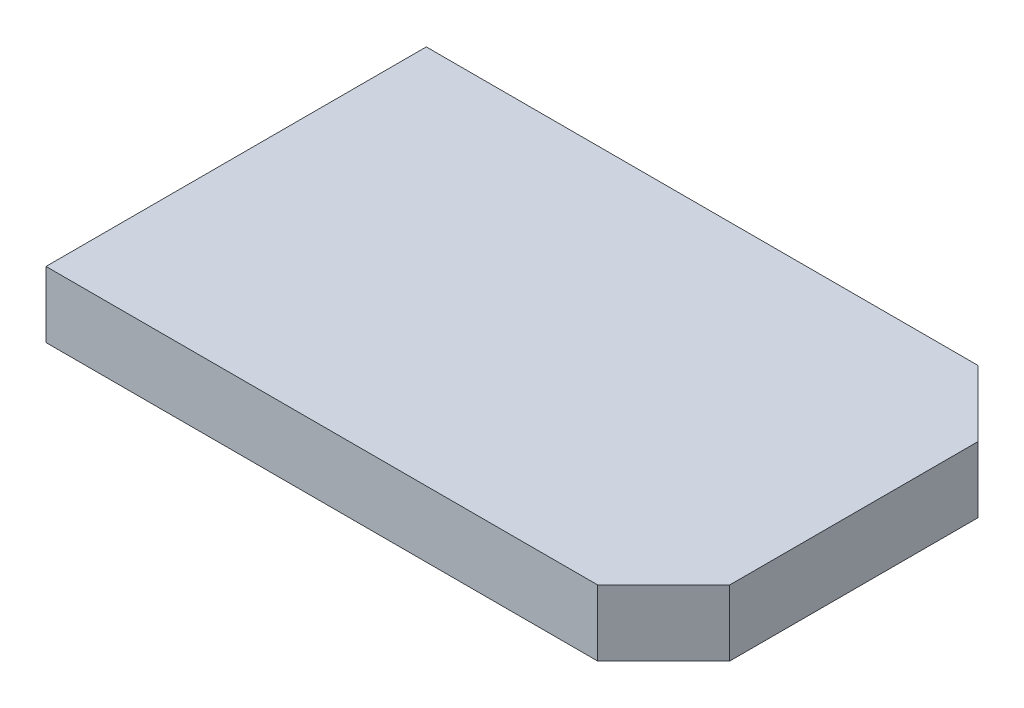
from build123d import *

# Parameters (mm, degrees)
SKETCH1_W           = 112.384257698
SKETCH1_H           = 69.188872884
BOSS_EXTRUDE1_DEPTH = 12
CHAMFER3_SIZE       = 12
CHAMFER4_SIZE       = 12


with BuildPart() as part:
    # Sketch1 → Boss-Extrude1 (new body)
    with BuildSketch(Plane(origin=(0, 0, 0), x_dir=(1, 0, 0), z_dir=(0, 1, 0))):
        Rectangle(SKETCH1_W, SKETCH1_H)
    extrude(amount=BOSS_EXTRUDE1_DEPTH)

    # Chamfer3
    chamfer3_edges = [part.edges().sort_by_distance(p)[0] for p in [
        (56.192128849, 6, 34.594436442),
    ]]
    chamfer(chamfer3_edges, length=CHAMFER3_SIZE)

    # Chamfer4
    chamfer4_edges = [part.edges().sort_by_distance(p)[0] for p in [
        (56.192128849, 6, -34.594436442),
    ]]
    chamfer(chamfer4_edges, length=CHAMFER4_SIZE)


solid = part.part
